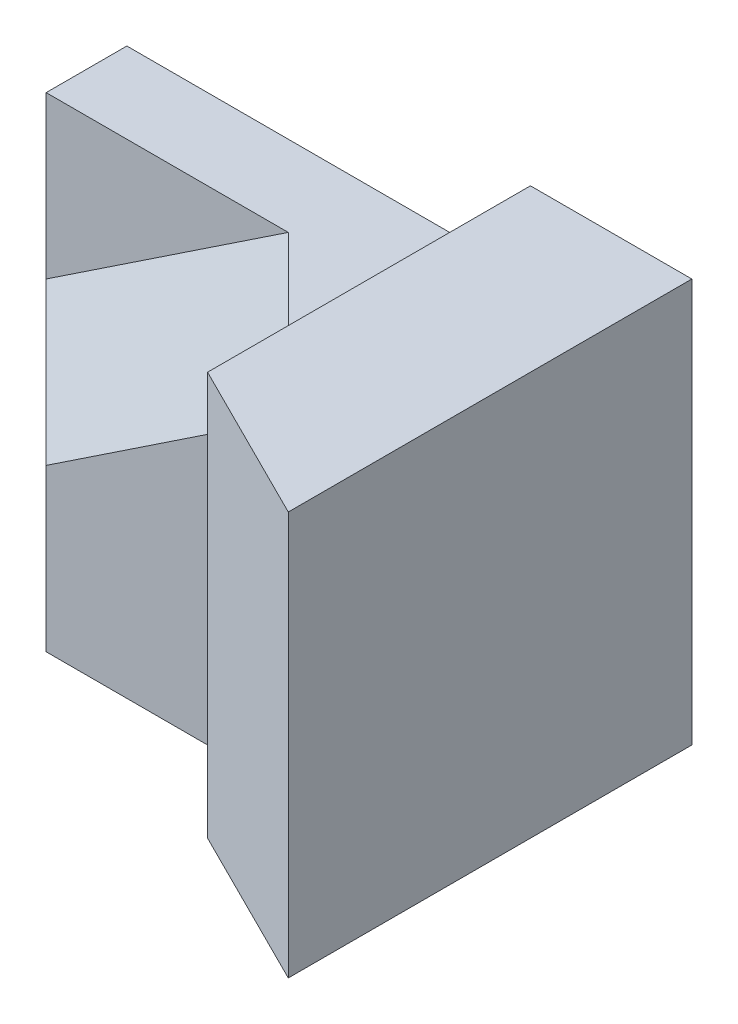
from build123d import *

# Parameters (mm, degrees)
SKETCH1_W            = 70
SKETCH1_H            = 50
BOSS_EXTRUDE1_DEPTH  = 50
SKETCH2_W            = 50
SKETCH2_H            = 10
CUT_EXTRUDE1_DEPTH   = 50
SKETCH3_W            = 50
SKETCH3_H            = 40
CUT_EXTRUDE2_DEPTH   = 40
CUT_EXTRUDE6_DEPTH   = 20
BOSS_EXTRUDE9_DEPTH  = 20
BOSS_EXTRUDE10_DEPTH = 20
SKETCH11_W           = 20
SKETCH11_H           = 20
CUT_EXTRUDE7_DEPTH   = 20
BOSS_EXTRUDE12_DEPTH = 10
BOSS_EXTRUDE13_DEPTH = 10
CUT_EXTRUDE8_DEPTH   = 68


with BuildPart() as part:
    # Sketch1 → Boss-Extrude1 (new body)
    with BuildSketch(Plane.XY):
        with Locations((35, 25)):
            Rectangle(SKETCH1_W, SKETCH1_H)
    extrude(amount=BOSS_EXTRUDE1_DEPTH)

    # Sketch2 → Cut-Extrude1 (cut)
    with BuildSketch(Plane.XY.offset(50)):
        with Locations((25, 45)):
            Rectangle(SKETCH2_W, SKETCH2_H)
    extrude(amount=-CUT_EXTRUDE1_DEPTH, mode=Mode.SUBTRACT)

    # Sketch3 → Cut-Extrude2 (cut)
    with BuildSketch(Plane.XY.offset(50)):
        with Locations((25, 20)):
            Rectangle(SKETCH3_W, SKETCH3_H)
    extrude(amount=-CUT_EXTRUDE2_DEPTH, mode=Mode.SUBTRACT)

    # Sketch8 → Cut-Extrude6 (cut)
    with BuildSketch(Plane.XY.offset(10)):
        Polygon((30, 40), (0, 20), (20, 20), (50, 40), align=None)
    extrude(amount=-CUT_EXTRUDE6_DEPTH, mode=Mode.SUBTRACT)

    # Sketch9 → Boss-Extrude9 (add)
    with BuildSketch(Plane.XY.offset(10)):
        Polygon((50, 40), (20, 20), (20, 0), (50, 0), align=None)
    extrude(amount=BOSS_EXTRUDE9_DEPTH)

    # Sketch10 → Boss-Extrude10 (add)
    with BuildSketch(Plane(origin=(-9.411764706, 14.117647059, 9.411764706), x_dir=(0.874474632, 0.403603676, 0.269069118), z_dir=(-0.48507125, 0.727606875, 0.48507125))):
        Polygon((45.069077198, 13.867504906), (67.939952194, -2.773500981), (33.6336397, -13.867504906), (10.762764704, 2.773500981), align=None)
    extrude(amount=-BOSS_EXTRUDE10_DEPTH)

    # Sketch11 → Cut-Extrude7 (cut)
    with BuildSketch(Plane.ZY.offset(-20)):
        with Locations((20, 10)):
            Rectangle(SKETCH11_W, SKETCH11_H)
    extrude(amount=CUT_EXTRUDE7_DEPTH, mode=Mode.SUBTRACT)

    # Sketch12 → Boss-Extrude12 (add)
    with BuildSketch(Plane(origin=(0, 0, 0), x_dir=(-1, 0, 0), z_dir=(0, 0, -1))):
        Polygon((-50, 40), (-20, 20), (0, 20), (-30, 40), align=None)
    extrude(amount=-BOSS_EXTRUDE12_DEPTH)

    # Sketch13 → Boss-Extrude13 (add)
    with BuildSketch(Plane(origin=(0, 40, 0), x_dir=(1, 0, 0), z_dir=(0, 1, 0))):
        Polygon((30, -10), (50, -10), (50, -30), align=None)
    extrude(amount=-BOSS_EXTRUDE13_DEPTH)

    # Sketch14 → Cut-Extrude8 (cut)
    with BuildSketch(Plane(origin=(0, 50, 0), x_dir=(1, 0, 0), z_dir=(0, 1, 0))):
        Polygon((70, -50), (50, -40), (50, -50), align=None)
    extrude(amount=-CUT_EXTRUDE8_DEPTH, mode=Mode.SUBTRACT)


solid = part.part
